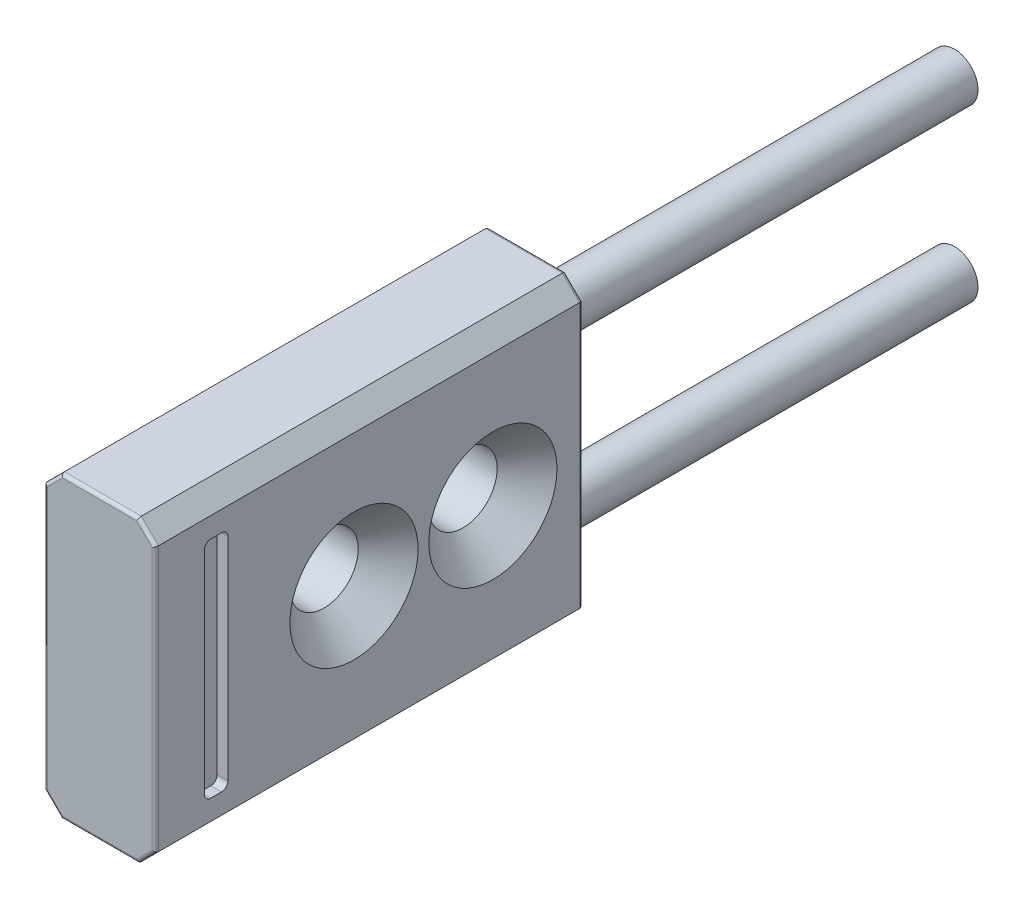
from build123d import *

# Parameters (mm, degrees)
SKETCH1_W                      = 20
SKETCH1_H                      = 14
BOSS_EXTRUDE1_DEPTH            = 5.2
SKETCH2_W                      = 1.1
SKETCH2_H                      = 10.5
CUT_EXTRUDE1_DEPTH             = 0.5
SKETCH3_W                      = 1.1
SKETCH3_H                      = 20
SKETCH4_W                      = 1.1
SKETCH4_H                      = 20
F_3_2_3_2_DIAMETER_HOLE1_D     = 3.2
F_3_2_3_2_DIAMETER_HOLE1_DEPTH = 5.2
CHAMFER1_SIZE                  = 0.8
CHAMFER2_SIZE                  = 1.4
FILLET1_R                      = 0.15
FILLET2_R                      = 0.3


with BuildPart() as part:
    # Sketch1 → Boss-Extrude1 (new body)
    with BuildSketch(Plane(origin=(0, 0, 0), x_dir=(0, 0, -1), z_dir=(1, 0, 0))):
        with Locations((7.1, 0)):
            Rectangle(SKETCH1_W, SKETCH1_H)
    extrude(amount=-BOSS_EXTRUDE1_DEPTH)

    # Sketch2 → Cut-Extrude1 (cut)
    with BuildSketch(Plane(origin=(0, 0, 0), x_dir=(0, 0, -1), z_dir=(1, 0, 0))):
        with Locations((-0.05, 0)):
            Rectangle(SKETCH2_W, SKETCH2_H)
    extrude(amount=-CUT_EXTRUDE1_DEPTH, mode=Mode.SUBTRACT)

    # Sketch3 → Revolve1 (revolve)
    with BuildSketch(Plane(origin=(0, -4, 0), x_dir=(1, 0, 0), z_dir=(0, 1, 0))):
        with Locations((-2.05, 27.1)):
            Rectangle(SKETCH3_W, SKETCH3_H)
    revolve(axis=Axis((-2.6, -4, -37.1), (0, 0, 1)))

    # Sketch4 → Revolve2 (revolve)
    with BuildSketch(Plane(origin=(0, 4, 0), x_dir=(1, 0, 0), z_dir=(0, 1, 0))):
        with Locations((-2.05, 27.1)):
            Rectangle(SKETCH4_W, SKETCH4_H)
    revolve(axis=Axis((-2.6, 4, -37.1), (0, 0, 1)))

    # Ø3.2 (3.2) Diameter Hole1
    with Locations(Plane(origin=(0, 0, 0), x_dir=(0, 0, -1), z_dir=(1, 0, 0))):
        with Locations((12.9, 0), (6.4, 0)):
            Hole(F_3_2_3_2_DIAMETER_HOLE1_D / 2, depth=F_3_2_3_2_DIAMETER_HOLE1_DEPTH)

    # Chamfer1
    chamfer1_edges = [part.edges().sort_by_distance(p)[0] for p in [
        (-5.2, 7, -7.1),
        (-5.2, -7, -7.1),
        (0, 7, -7.1),
        (0, -7, -7.1),
    ]]
    chamfer(chamfer1_edges, length=CHAMFER1_SIZE)

    # Chamfer2
    chamfer2_edges = [part.edges().sort_by_distance(p)[0] for p in [
        (0, 0, -8),
        (0, 0, -14.5),
    ]]
    chamfer(chamfer2_edges, length=CHAMFER2_SIZE)

    # Fillet1
    fillet1_edges = [part.edges().sort_by_distance(p)[0] for p in [
        (0, 0, -17.1),
        (0, 0, 2.9),
        (-2.6, 7, 2.9),
        (-5.2, 0, 2.9),
        (-2.6, -7, 2.9),
        (-4.8, 6.6, 2.9),
        (-4.8, -6.6, 2.9),
        (-0.4, -6.6, 2.9),
        (-0.4, 6.6, 2.9),
        (-2.6, 7, -17.1),
        (-2.6, -7, -17.1),
        (-5.2, 0, -17.1),
        (-4.8, 6.6, -17.1),
        (-4.8, -6.6, -17.1),
        (-0.4, -6.6, -17.1),
        (-0.4, 6.6, -17.1),
    ]]
    fillet(fillet1_edges, radius=FILLET1_R)

    # Fillet2
    fillet2_edges = [part.edges().sort_by_distance(p)[0] for p in [
        (-0.25, -5.25, -0.5),
        (-0.25, -5.25, 0.6),
        (-0.25, 5.25, 0.6),
        (-0.25, 5.25, -0.5),
    ]]
    fillet(fillet2_edges, radius=FILLET2_R)


solid = part.part
